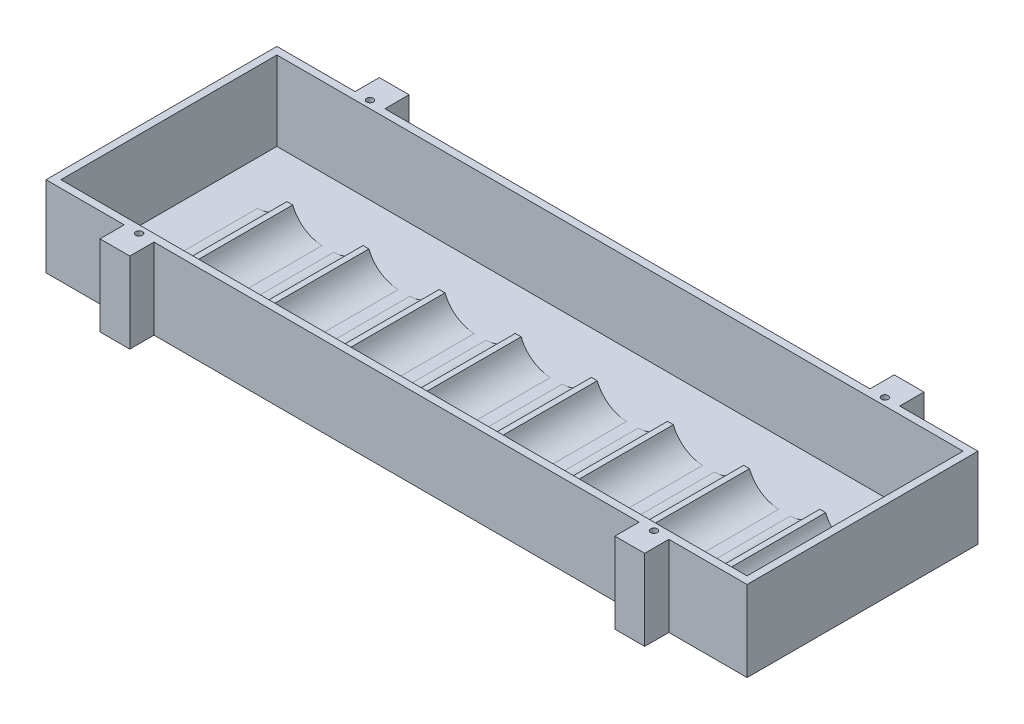
from build123d import *

# Parameters (mm, degrees)
SKETCH1_W                 = 239.08
SKETCH1_H                 = 78.74
BOSS_EXTRUDE1_DEPTH       = 0.508
SKETCH1_3_W               = 239.08
SKETCH1_3_H               = 8.255
SKETCH1_3_H_2             = 78.74
SKETCH1_3_W_2             = 234
SKETCH1_3_H_3             = 73.66
BOSS_EXTRUDE2_DEPTH       = 27
BOSS_EXTRUDE3_START       = 21.59
BOSS_EXTRUDE3_DEPTH       = 32.5
SKETCH1_4_W               = 239.08
SKETCH1_4_H               = 8.255
BOSS_EXTRUDE4_DEPTH       = 0.508
F_4_40_TAPPED_HOLE2_D     = 2.2606
F_4_40_TAPPED_HOLE2_DEPTH = 7.62
F_4_40_TAPPED_HOLE2_TIP   = 0.679152758
SKETCH13_W                = 165.42
SKETCH13_H                = 8.255
SKETCH13_W_2              = 26.67
CUT_EXTRUDE1_DEPTH        = 28.508


with BuildPart() as part:
    # Sketch1 → Boss-Extrude1 (new body)
    with BuildSketch(Plane(origin=(0, 0, 0), x_dir=(1, 0, 0), z_dir=(0, 1, 0))):
        with Locations((119.54, -39.37)):
            Rectangle(SKETCH1_W, SKETCH1_H)
    extrude(amount=-BOSS_EXTRUDE1_DEPTH)

    # Sketch1_3 → Boss-Extrude2 (add)
    with BuildSketch(Plane(origin=(0, 0, 0), x_dir=(1, 0, 0), z_dir=(0, 1, 0))):
        with Locations((119.54, 4.1275)):
            Rectangle(SKETCH1_3_W, SKETCH1_3_H)
        with Locations((119.54, -82.8675)):
            Rectangle(SKETCH1_3_W, SKETCH1_3_H)
        with Locations((119.54, -39.37)):
            Rectangle(SKETCH1_3_W, SKETCH1_3_H_2)
        with Locations((119.54, -39.37)):
            Rectangle(SKETCH1_3_W_2, SKETCH1_3_H_3, mode=Mode.SUBTRACT)
    extrude(amount=BOSS_EXTRUDE2_DEPTH)

    # Sketch5 → Boss-Extrude3 (add)
    with BuildSketch(Plane.XY.offset(2.54).offset(BOSS_EXTRUDE3_START)):
        with BuildLine():
            Line((29.54, 7), (27.54, 7))
            ThreePointArc((27.54, 7), (23.600043647, 1.985651932), (17.54, 0))
            Line((17.54, 0), (39.54, 0))
            ThreePointArc((39.54, 0), (33.479956353, 1.985651932), (29.54, 7))
        make_face()
        with BuildLine():
            Line((55.4988, 7), (53.4988, 7))
            ThreePointArc((53.4988, 7), (49.558843647, 1.985651932), (43.4988, 0))
            Line((43.4988, 0), (65.4988, 0))
            ThreePointArc((65.4988, 0), (59.438756353, 1.985651932), (55.4988, 7))
        make_face()
        with BuildLine():
            Line((81.4576, 7), (79.4576, 7))
            ThreePointArc((79.4576, 7), (75.517643647, 1.985651932), (69.4576, 0))
            Line((69.4576, 0), (91.4576, 0))
            ThreePointArc((91.4576, 0), (85.397556353, 1.985651932), (81.4576, 7))
        make_face()
        with BuildLine():
            Line((107.4164, 7), (105.4164, 7))
            ThreePointArc((105.4164, 7), (101.476443647, 1.985651932), (95.4164, 0))
            Line((95.4164, 0), (117.4164, 0))
            ThreePointArc((117.4164, 0), (111.356356353, 1.985651932), (107.4164, 7))
        make_face()
        with BuildLine():
            Line((133.3752, 7), (131.3752, 7))
            ThreePointArc((131.3752, 7), (127.435243647, 1.985651932), (121.3752, 0))
            Line((121.3752, 0), (143.3752, 0))
            ThreePointArc((143.3752, 0), (137.315156353, 1.985651932), (133.3752, 7))
        make_face()
        with BuildLine():
            Line((159.334, 7), (157.334, 7))
            ThreePointArc((157.334, 7), (153.394043647, 1.985651932), (147.334, 0))
            Line((147.334, 0), (169.334, 0))
            ThreePointArc((169.334, 0), (163.273956353, 1.985651932), (159.334, 7))
        make_face()
        with BuildLine():
            Line((185.2928, 7), (183.2928, 7))
            ThreePointArc((183.2928, 7), (179.352843647, 1.985651932), (173.2928, 0))
            Line((173.2928, 0), (195.2928, 0))
            ThreePointArc((195.2928, 0), (189.232756353, 1.985651932), (185.2928, 7))
        make_face()
        with BuildLine():
            Line((211.2516, 7), (209.2516, 7))
            ThreePointArc((209.2516, 7), (205.311643647, 1.985651932), (199.2516, 0))
            Line((199.2516, 0), (221.2516, 0))
            ThreePointArc((221.2516, 0), (215.191556353, 1.985651932), (211.2516, 7))
        make_face()
    extrude(amount=BOSS_EXTRUDE3_DEPTH)

    # Sketch1_4 → Boss-Extrude4 (add)
    with BuildSketch(Plane(origin=(0, 0, 0), x_dir=(1, 0, 0), z_dir=(0, 1, 0))):
        with Locations((119.54, 4.1275)):
            Rectangle(SKETCH1_4_W, SKETCH1_4_H)
        with Locations((119.54, -82.8675)):
            Rectangle(SKETCH1_4_W, SKETCH1_4_H)
    extrude(amount=-BOSS_EXTRUDE4_DEPTH)

    # 4-40 Tapped Hole2
    with Locations(Plane(origin=(0, 27, 0), x_dir=(-1, 0, 0), z_dir=(0, 1, 0))):
        with Locations((-31.75, 0), (-207.33, 0), (-31.75, 78.74), (-207.33, 78.74)):
            Hole(F_4_40_TAPPED_HOLE2_D / 2, depth=F_4_40_TAPPED_HOLE2_DEPTH)
            with Locations((0, 0, -(F_4_40_TAPPED_HOLE2_DEPTH + F_4_40_TAPPED_HOLE2_TIP / 2))):  # 118° drill point
                Cone(0, F_4_40_TAPPED_HOLE2_D / 2, F_4_40_TAPPED_HOLE2_TIP, mode=Mode.SUBTRACT)

    # Sketch13 → Cut-Extrude1 (cut, through all)
    with BuildSketch(Plane(origin=(0, 27, 0), x_dir=(1, 0, 0), z_dir=(0, 1, 0))):
        with Locations((119.54, 4.1275)):
            Rectangle(SKETCH13_W, SKETCH13_H)
        with Locations((119.54, -82.8675)):
            Rectangle(SKETCH13_W, SKETCH13_H)
        with Locations((13.335, 4.1275)):
            Rectangle(SKETCH13_W_2, SKETCH13_H)
        with Locations((225.745, 4.1275)):
            Rectangle(SKETCH13_W_2, SKETCH13_H)
        with Locations((225.745, -82.8675)):
            Rectangle(SKETCH13_W_2, SKETCH13_H)
        with Locations((13.335, -82.8675)):
            Rectangle(SKETCH13_W_2, SKETCH13_H)
    extrude(amount=-CUT_EXTRUDE1_DEPTH, mode=Mode.SUBTRACT)


solid = part.part
